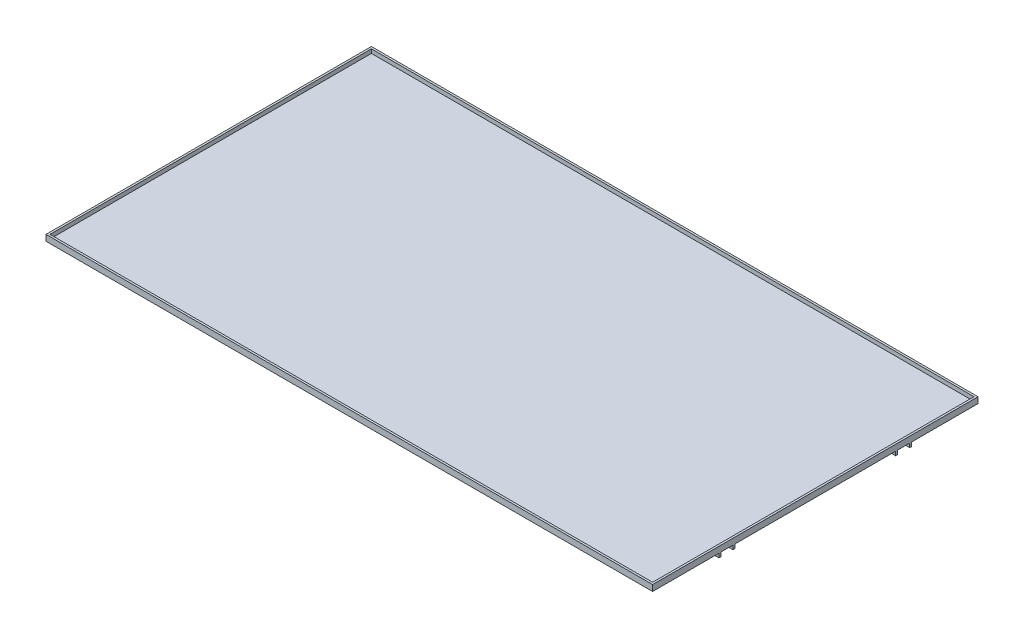
from build123d import *

# Parameters (mm, degrees)
SKETCH2_W                 = 1510
SKETCH2_H                 = 810
SKETCH2_W_2               = 1500
SKETCH2_H_2               = 800
BOSS_EXTRUDE1_DEPTH       = 10
SKETCH3_W                 = 1510
SKETCH3_H                 = 810
SKETCH3_W_2               = 1460
SKETCH3_H_2               = 140
SKETCH3_W_3               = 30
SKETCH3_H_3               = 400
SKETCH3_W_4               = 1200
BOSS_EXTRUDE2_DEPTH       = 5
SKETCH5_W                 = 1510
SKETCH5_H                 = 5
BOSS_EXTRUDE3_DEPTH       = 10
LPATTERN1_COUNT           = 2
LPATTERN1_PITCH           = 35
LPATTERN2_COUNT           = 2
LPATTERN2_PITCH           = 440
LPATTERN2_COPY_1_SKETCH_W = 1510
LPATTERN2_COPY_1_SKETCH_H = 5
LPATTERN2_COPY_1_DEPTH    = 10
SKETCH6_R                 = 10
BOSS_EXTRUDE4_DEPTH       = 5
LPATTERN3_COUNT           = 2
LPATTERN3_PITCH           = 440
SKETCH8_R                 = 10
BOSS_EXTRUDE5_DEPTH       = 25
SKETCH9_W                 = 80
SKETCH9_H                 = 400
BOSS_EXTRUDE6_DEPTH       = 5
SKETCH10_R                = 10
BOSS_EXTRUDE7_DEPTH       = 12.5
SKETCH12_W                = 400
SKETCH12_H                = 5
BOSS_EXTRUDE8_DEPTH       = 100
FILLET3_R                 = 10
FILLET4_R                 = 10
FILLET5_R                 = 10
FILLET6_R                 = 10
SKETCH13_W                = 1460
SKETCH13_H                = 140
SKETCH13_W_2              = 800
SKETCH13_H_2              = 400
SKETCH13_W_3              = 30
SKETCH13_W_4              = 220
BOSS_EXTRUDE9_DEPTH       = 5


with BuildPart() as part:
    # Sketch2 → Boss-Extrude1 (new body)
    with BuildSketch(Plane(origin=(0, 0, 0), x_dir=(1, 0, 0), z_dir=(0, 1, 0))):
        Rectangle(SKETCH2_W, SKETCH2_H)
        Rectangle(SKETCH2_W_2, SKETCH2_H_2, mode=Mode.SUBTRACT)
    extrude(amount=BOSS_EXTRUDE1_DEPTH)

    # Sketch3 → Boss-Extrude2 (add)
    with BuildSketch(Plane(origin=(0, 0, 0), x_dir=(1, 0, 0), z_dir=(0, 1, 0))):
        Rectangle(SKETCH3_W, SKETCH3_H)
        with Locations((0, -310)):
            Rectangle(SKETCH3_W_2, SKETCH3_H_2, mode=Mode.SUBTRACT)
        with Locations((0, 310)):
            Rectangle(SKETCH3_W_2, SKETCH3_H_2, mode=Mode.SUBTRACT)
        with Locations((-715, 0)):
            Rectangle(SKETCH3_W_3, SKETCH3_H_3, mode=Mode.SUBTRACT)
        with Locations((715, 0)):
            Rectangle(SKETCH3_W_3, SKETCH3_H_3, mode=Mode.SUBTRACT)
        Rectangle(SKETCH3_W_4, SKETCH3_H_3, mode=Mode.SUBTRACT)
    extrude(amount=-BOSS_EXTRUDE2_DEPTH)

    # Sketch5 → Boss-Extrude3 (add)
    with BuildSketch(Plane.XZ.offset(5)):
        with Locations((0, 237.5)):
            Rectangle(SKETCH5_W, SKETCH5_H)
    boss_extrude3 = extrude(amount=BOSS_EXTRUDE3_DEPTH)

    # LPattern1: Boss-Extrude3 ×2
    with Locations(*[(0, 0, -i * LPATTERN1_PITCH) for i in range(1, LPATTERN1_COUNT)]):
        add(boss_extrude3)

    # LPattern2: Boss-Extrude3 ×2
    with Locations(*[(0, 0, -i * LPATTERN2_PITCH) for i in range(1, LPATTERN2_COUNT)]):
        add(boss_extrude3)

    # LPattern2 copy 1 sketch → LPattern2 copy 1 (add)
    with BuildSketch(Plane(origin=(0, -5, -475), x_dir=(1, 0, 0), z_dir=(0, -1, 0))):
        with Locations((0, 237.5)):
            Rectangle(LPATTERN2_COPY_1_SKETCH_W, LPATTERN2_COPY_1_SKETCH_H)
    extrude(amount=LPATTERN2_COPY_1_DEPTH)

    # Sketch6 → Boss-Extrude4 (add, symmetric)
    with BuildSketch(Plane.XY.offset(220)):
        with BuildLine():
            Line((630, -5), (630, -35))
            ThreePointArc((630, -35), (650, -55), (670, -35))
            Line((670, -35), (670, -5))
            Line((670, -5), (630, -5))
        make_face()
        with Locations((650, -35)):
            Circle(SKETCH6_R, mode=Mode.SUBTRACT)
    boss_extrude4 = extrude(amount=BOSS_EXTRUDE4_DEPTH, both=True)

    # LPattern3: Boss-Extrude4 ×2
    with Locations(*[(0, 0, -i * LPATTERN3_PITCH) for i in range(1, LPATTERN3_COUNT)]):
        add(boss_extrude4)

    # Sketch8 → Boss-Extrude5 (add)
    with BuildSketch(Plane.ZY.offset(755)):
        with BuildLine():
            Line((-25, -35), (-25, -5))
            Line((-25, -5), (25, -5))
            Line((25, -5), (25, -35))
            ThreePointArc((25, -35), (0, -60), (-25, -35))
        make_face()
        with Locations((0, -35)):
            Circle(SKETCH8_R, mode=Mode.SUBTRACT)
    extrude(amount=-BOSS_EXTRUDE5_DEPTH)

    # Sketch9 → Boss-Extrude6 (add)
    with BuildSketch(Plane(origin=(0, 0, 0), x_dir=(1, 0, 0), z_dir=(0, 1, 0))):
        with Locations((240, 0)):
            Rectangle(SKETCH9_W, SKETCH9_H)
    extrude(amount=-BOSS_EXTRUDE6_DEPTH)

    # Sketch10 → Boss-Extrude7 (add, symmetric)
    with BuildSketch(Plane.ZY.offset(-240)):
        with BuildLine():
            Line((25, -5), (25, -35))
            ThreePointArc((25, -35), (0, -60), (-25, -35))
            Line((-25, -35), (-25, -5))
            Line((-25, -5), (25, -5))
        make_face()
        with Locations((0, -35)):
            Circle(SKETCH10_R, mode=Mode.SUBTRACT)
    extrude(amount=BOSS_EXTRUDE7_DEPTH, both=True)

    # Sketch12 → Boss-Extrude8 (add)
    with BuildSketch(Plane(origin=(280, 0, 0), x_dir=(0, 0, -1), z_dir=(1, 0, 0))):
        with Locations((0, -2.5)):
            Rectangle(SKETCH12_W, SKETCH12_H)
    extrude(amount=BOSS_EXTRUDE8_DEPTH)

    # Fillet3
    fillet3_edges = [part.edges().sort_by_distance(p)[0] for p in [
        (240, -5, 25),
    ]]
    fillet(fillet3_edges, radius=FILLET3_R)

    # Fillet4
    fillet4_edges = [part.edges().sort_by_distance(p)[0] for p in [
        (240, -5, -25),
    ]]
    fillet(fillet4_edges, radius=FILLET4_R)

    # Fillet5
    fillet5_edges = [part.edges().sort_by_distance(p)[0] for p in [
        (-742.5, -5, 25),
    ]]
    fillet(fillet5_edges, radius=FILLET5_R)

    # Fillet6
    fillet6_edges = [part.edges().sort_by_distance(p)[0] for p in [
        (-742.5, -5, -25),
    ]]
    fillet(fillet6_edges, radius=FILLET6_R)

    # Sketch13 → Boss-Extrude9 (add)
    with BuildSketch(Plane.XZ.offset(5)):
        with Locations((0, 310)):
            Rectangle(SKETCH13_W, SKETCH13_H)
        with Locations((0, -310)):
            Rectangle(SKETCH13_W, SKETCH13_H)
        with Locations((-200, 0)):
            Rectangle(SKETCH13_W_2, SKETCH13_H_2)
        with Locations((-715, 0)):
            Rectangle(SKETCH13_W_3, SKETCH13_H_2)
        with Locations((490, 0)):
            Rectangle(SKETCH13_W_4, SKETCH13_H_2)
        with Locations((715, 0)):
            Rectangle(SKETCH13_W_3, SKETCH13_H_2)
    extrude(amount=-BOSS_EXTRUDE9_DEPTH)


solid = part.part
